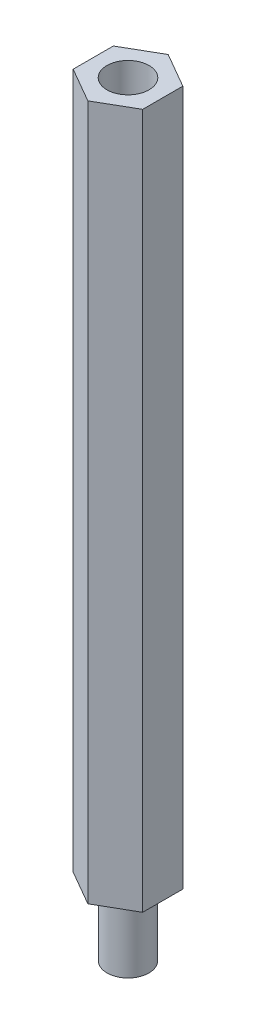
from build123d import *

# Parameters (mm, degrees)
BOSS_EXTRUDE1_DEPTH = 50
SKETCH2_R           = 1.516102493
CUT_EXTRUDE1_DEPTH  = 10
SKETCH3_R           = 1.505855903
BOSS_EXTRUDE2_DEPTH = 5


with BuildPart() as part:
    # Sketch1 → Boss-Extrude1 (new body)
    with BuildSketch(Plane(origin=(0, 0, 0), x_dir=(1, 0, 0), z_dir=(0, 1, 0))):
        Polygon((0, -2.886751346), (2.5, -1.443375673), (2.5, 1.443375673), (0, 2.886751346), (-2.5, 1.443375673), (-2.5, -1.443375673), align=None)
    extrude(amount=BOSS_EXTRUDE1_DEPTH)

    # Sketch2 → Cut-Extrude1 (cut)
    with BuildSketch(Plane(origin=(0, 50, 0), x_dir=(1, 0, 0), z_dir=(0, 1, 0))):
        Circle(SKETCH2_R)
    extrude(amount=-CUT_EXTRUDE1_DEPTH, mode=Mode.SUBTRACT)

    # Sketch3 → Boss-Extrude2 (add)
    with BuildSketch(Plane.XZ):
        Circle(SKETCH3_R)
    extrude(amount=BOSS_EXTRUDE2_DEPTH)


solid = part.part
